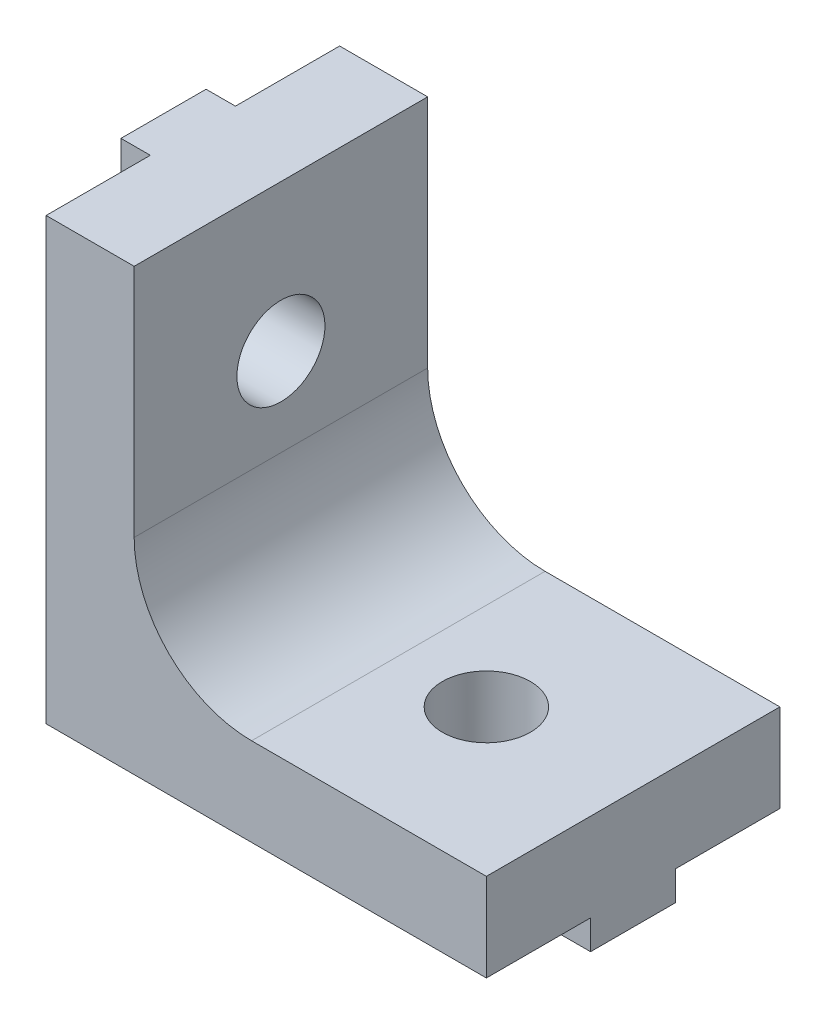
from build123d import *

# Parameters (mm, degrees)
MAIN_DEPTH                         = 10
ESQUISSE4_W                        = 2.9
ESQUISSE4_H                        = 15
MAKERBEAMFIXVERTICAL_DEPTH         = 1
ESQUISSE2_R                        = 1.5
MAKERBEAMVERTICALHOLE_DEPTH        = 2
MAKERBEAMVERTICALHOLE_DEPTH_BACK   = 16
ESQUISSE5_W                        = 15
ESQUISSE5_H                        = 2.9
MAKERBEAMFIXHORIZONTAL_DEPTH       = 1
ESQUISSE3_R                        = 1.5
MAKERBEAMHORIZONTALHOLE_DEPTH      = 2
MAKERBEAMHORIZONTALHOLE_DEPTH_BACK = 16


with BuildPart() as part:
    # Esquisse1 → Main (new body)
    with BuildSketch(Plane.XY):
        with BuildLine():
            Line((0, 0), (15, 0))
            Line((15, 0), (15, 3))
            Line((15, 3), (7, 3))
            ThreePointArc((7, 3), (4.171572875, 4.171572875), (3, 7))
            Line((3, 7), (3, 15))
            Line((3, 15), (0, 15))
            Line((0, 15), (0, 0))
        make_face()
    extrude(amount=MAIN_DEPTH)

    # Esquisse4 → MakerBeamFixVertical (add)
    with BuildSketch(Plane.ZY):
        with Locations((5, 7.5)):
            Rectangle(ESQUISSE4_W, ESQUISSE4_H)
    extrude(amount=MAKERBEAMFIXVERTICAL_DEPTH)

    # Esquisse2 → MakerBeamVerticalHole (cut, two sides)
    with BuildSketch(Plane.ZY) as makerbeamverticalhole_sk:
        with Locations((5, 10)):
            Circle(ESQUISSE2_R)
    extrude(amount=MAKERBEAMVERTICALHOLE_DEPTH, mode=Mode.SUBTRACT)
    extrude(makerbeamverticalhole_sk.sketch, amount=-MAKERBEAMVERTICALHOLE_DEPTH_BACK, mode=Mode.SUBTRACT)

    # Esquisse5 → MakerBeamFixHorizontal (add)
    with BuildSketch(Plane(origin=(0, 0, 0), x_dir=(-1, 0, 0), z_dir=(0, -1, 0))):
        with Locations((-7.5, -5)):
            Rectangle(ESQUISSE5_W, ESQUISSE5_H)
    extrude(amount=MAKERBEAMFIXHORIZONTAL_DEPTH)

    # Esquisse3 → MakerBeamHorizontalHole (cut, two sides)
    with BuildSketch(Plane.XZ) as makerbeamhorizontalhole_sk:
        with Locations((10, 5)):
            Circle(ESQUISSE3_R)
    extrude(amount=MAKERBEAMHORIZONTALHOLE_DEPTH, mode=Mode.SUBTRACT)
    extrude(makerbeamhorizontalhole_sk.sketch, amount=-MAKERBEAMHORIZONTALHOLE_DEPTH_BACK, mode=Mode.SUBTRACT)


solid = part.part
